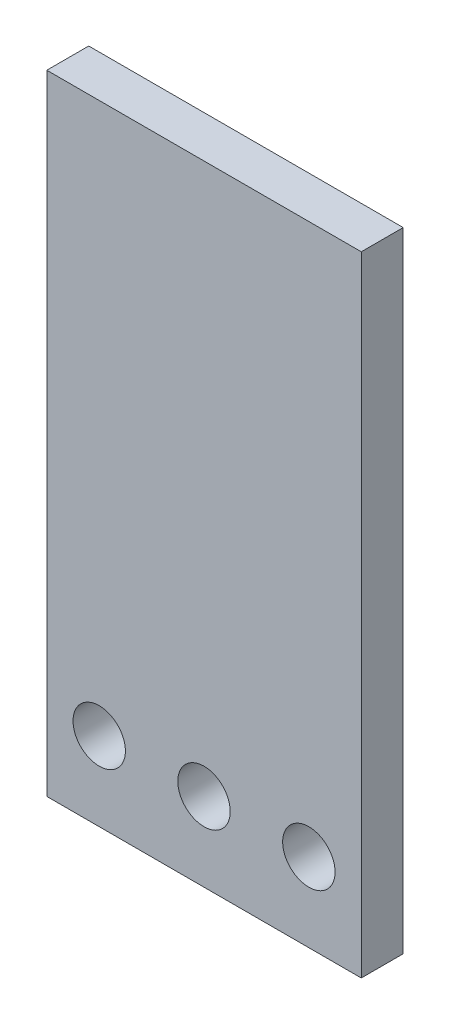
from build123d import *

# Parameters (mm, degrees)
SKETCH1_W           = 76.2
SKETCH1_H           = 152.4
SKETCH1_R           = 6.35
BOSS_EXTRUDE1_DEPTH = 10.16


with BuildPart() as part:
    # Sketch1 → Boss-Extrude1 (new body)
    with BuildSketch(Plane.XY):
        with Locations((38.1, 76.2)):
            Rectangle(SKETCH1_W, SKETCH1_H)
        with Locations((12.7, 19.05)):
            Circle(SKETCH1_R, mode=Mode.SUBTRACT)
        with Locations((38.1, 19.05)):
            Circle(SKETCH1_R, mode=Mode.SUBTRACT)
        with Locations((63.5, 19.05)):
            Circle(SKETCH1_R, mode=Mode.SUBTRACT)
    extrude(amount=BOSS_EXTRUDE1_DEPTH)


solid = part.part
